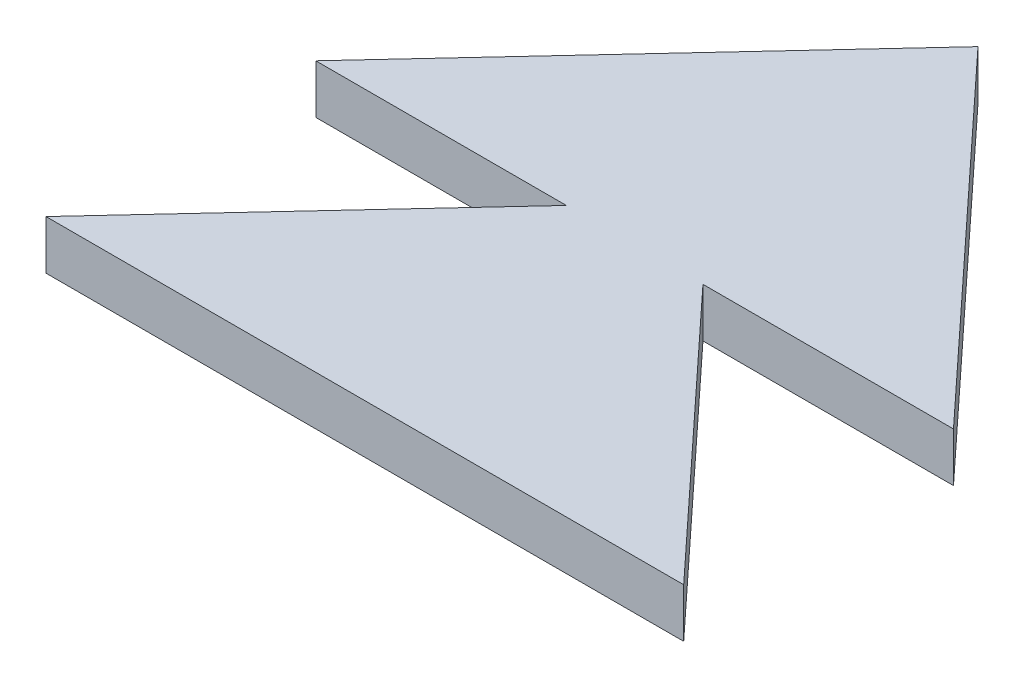
from build123d import *

# Parameters (mm, degrees)
BOSS_EXTRUDE2_DEPTH = 1


with BuildPart() as part:
    # Sketch2 → Boss-Extrude2 (new body)
    with BuildSketch(Plane(origin=(0, 0, 0), x_dir=(1, 0, 0), z_dir=(0, 1, 0))):
        Polygon((0, 0), (13, 0), (7.892857143, 5.5), (13, 5.5), (6.5, 12.5), (0, 5.5), (5.107142857, 5.5), align=None)
    extrude(amount=BOSS_EXTRUDE2_DEPTH)


solid = part.part
